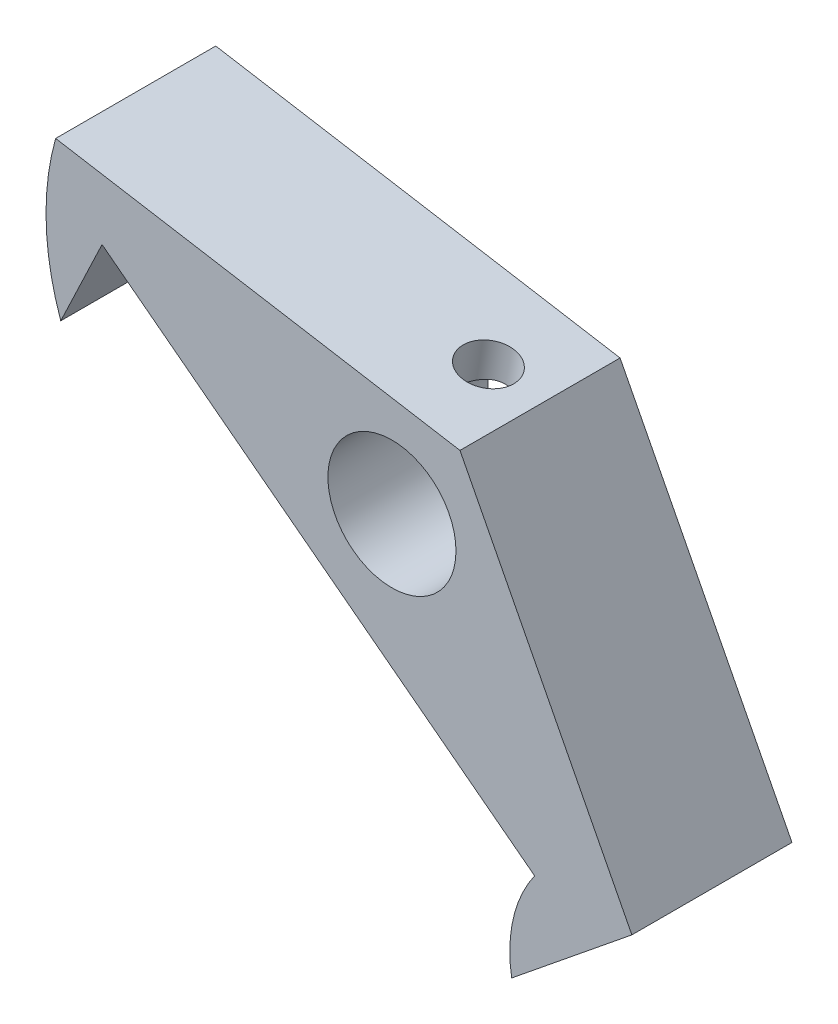
from build123d import *

# Parameters (mm, degrees)
SKETCH1_R                 = 2
BOSS_EXTRUDE1_DEPTH       = 5
M2X0_4_TAPPED_HOLE1_D     = 1.6
M2X0_4_TAPPED_HOLE1_DEPTH = 2.999994
M2X0_4_TAPPED_HOLE1_TIP   = 0.480688495


with BuildPart() as part:
    # Sketch1 → Boss-Extrude1 (new body)
    with BuildSketch(Plane.XY):
        with BuildLine():
            Line((7.49299434, 88.359418723), (2.124641235, 98.779265156))
            Line((2.124641235, 98.779265156), (-10.502416807, 100.902673639))
            ThreePointArc((-10.502416807, 100.902673639), (-10.798602236, 98.463827502), (-10.342383239, 96.049793427))
            Line((-10.342383239, 96.049793427), (-9.053191571, 98.758664935))
            Line((-9.053191571, 98.758664935), (4.456621188, 88.438669077))
            ThreePointArc((4.456621188, 88.438669077), (3.787347561, 86.94932011), (3.73945192, 85.317206897))
            Line((3.73945192, 85.317206897), (6.070083914, 87.206162828))
            Line((6.070083914, 87.206162828), (7.49299434, 88.359418723))
        make_face()
        with Locations((0, 95.99791663)):
            Circle(SKETCH1_R, mode=Mode.SUBTRACT)
    extrude(amount=BOSS_EXTRUDE1_DEPTH)

    # M2x0.4 Tapped Hole1
    with Locations(Plane(origin=(16.212659079, 96.410176767, 0), x_dir=(0.986153532, -0.16583489, 0), z_dir=(0.16583489, 0.986153532, 0))):
        with Locations((-15.919803906, -2.5)):
            Hole(M2X0_4_TAPPED_HOLE1_D / 2, depth=M2X0_4_TAPPED_HOLE1_DEPTH)
            with Locations((0, 0, -(M2X0_4_TAPPED_HOLE1_DEPTH + M2X0_4_TAPPED_HOLE1_TIP / 2))):  # 118° drill point
                Cone(0, M2X0_4_TAPPED_HOLE1_D / 2, M2X0_4_TAPPED_HOLE1_TIP, mode=Mode.SUBTRACT)


solid = part.part
